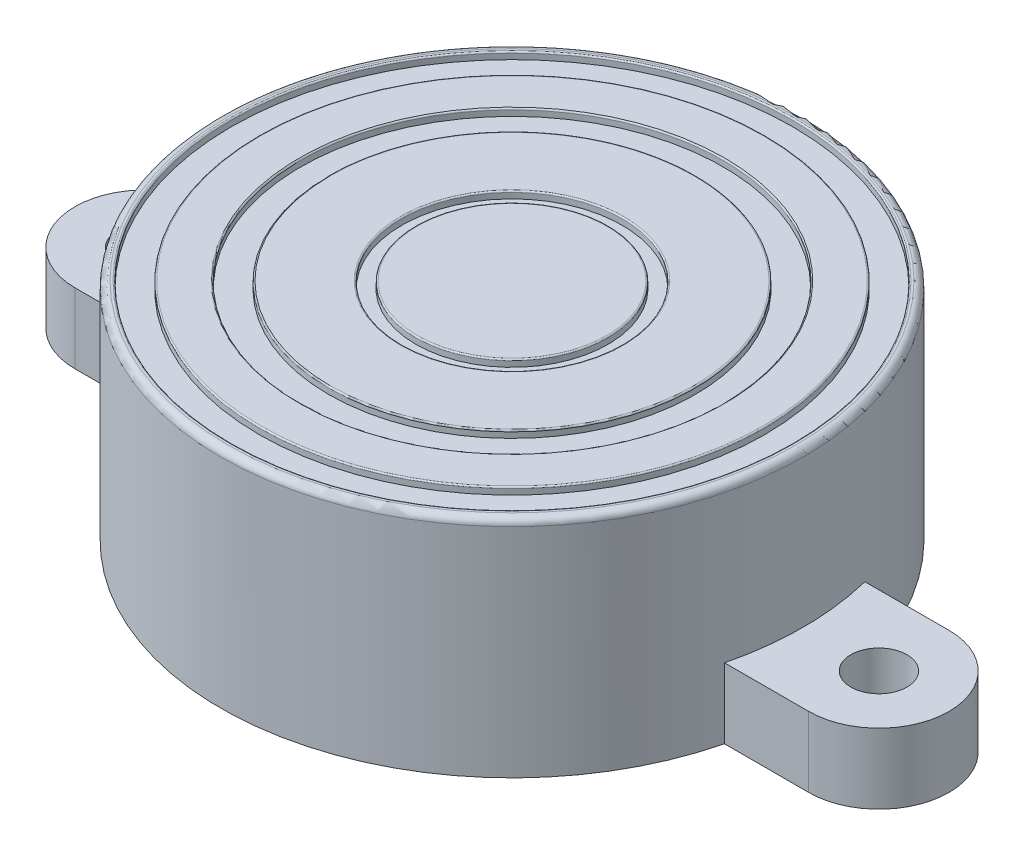
from build123d import *

# Parameters (mm, degrees)
SKETCH1_R           = 20.75
BOSS_EXTRUDE1_DEPTH = 16
SKETCH2_R           = 20
SKETCH2_R_2         = 18
SKETCH2_R_3         = 15.05
SKETCH2_R_4         = 13.05
SKETCH2_R_5         = 7.85
SKETCH2_R_6         = 6.85
CUT_EXTRUDE1_DEPTH  = 0.5
FILLET1_R           = 0.1
FILLET2_R           = 0.5
SKETCH3_R           = 5
BOSS_EXTRUDE2_DEPTH = 5
SKETCH4_R           = 2
CUT_EXTRUDE2_DEPTH  = 5


with BuildPart() as part:
    # Sketch1 → Boss-Extrude1 (new body)
    with BuildSketch(Plane(origin=(0, 0, 0), x_dir=(1, 0, 0), z_dir=(0, 1, 0))):
        with Locations(Location((0, 0, 0), (0, 0, 270))):
            Circle(SKETCH1_R)
    extrude(amount=BOSS_EXTRUDE1_DEPTH)

    # Sketch2 → Cut-Extrude1 (cut)
    with BuildSketch(Plane(origin=(0, 16, 0), x_dir=(1, 0, 0), z_dir=(0, 1, 0))):
        with Locations(Location((0, 0, 0), (0, 0, 270))):
            Circle(SKETCH2_R)
        with Locations(Location((0, 0, 0), (0, 0, 270))):
            Circle(SKETCH2_R_2, mode=Mode.SUBTRACT)
        with Locations(Location((0, 0, 0), (0, 0, 270))):
            Circle(SKETCH2_R_3)
        with Locations(Location((0, 0, 0), (0, 0, 270))):
            Circle(SKETCH2_R_4, mode=Mode.SUBTRACT)
        with Locations(Location((0, 0, 0), (0, 0, 270))):
            Circle(SKETCH2_R_5)
        with Locations(Location((0, 0, 0), (0, 0, 270))):
            Circle(SKETCH2_R_6, mode=Mode.SUBTRACT)
    extrude(amount=-CUT_EXTRUDE1_DEPTH, mode=Mode.SUBTRACT)

    # Fillet1
    fillet1_edges = [part.edges().sort_by_distance(p)[0] for p in [
        (0, 16, -18),
        (0, 16, -20),
        (0, 16, -13.05),
        (0, 16, -15.05),
        (0, 16, -6.85),
        (0, 16, -7.85),
    ]]
    fillet(fillet1_edges, radius=FILLET1_R)

    # Fillet2
    fillet2_edges = [part.edges().sort_by_distance(p)[0] for p in [
        (0, 16, -20.75),
    ]]
    fillet(fillet2_edges, radius=FILLET2_R)

    # Sketch3 → Boss-Extrude2 (add)
    with BuildSketch(Plane.XZ):
        with BuildLine():
            Line((-26.138582373, -5), (-20.138582373, -5))
            ThreePointArc((-20.138582373, -5), (-20.75, 0), (-20.138582373, 5))
            Line((-20.138582373, 5), (-26.138582373, 5))
            ThreePointArc((-26.138582373, 5), (-22.603048467, 3.535533906), (-21.138582373, 0))
            ThreePointArc((-21.138582373, 0), (-22.603048467, -3.535533906), (-26.138582373, -5))
        make_face()
        with BuildLine():
            ThreePointArc((20.75, 0), (20.596578408, -2.518622218), (20.138582373, -5))
            Line((20.138582373, -5), (26.138582373, -5))
            ThreePointArc((26.138582373, -5), (21.138582373, 0), (26.138582373, 5))
            Line((26.138582373, 5), (20.138582373, 5))
            ThreePointArc((20.138582373, 5), (20.596578408, 2.518622218), (20.75, 0))
        make_face()
        with Locations((-26.138582373, 0)):
            Circle(SKETCH3_R)
        with Locations((26.138582373, 0)):
            Circle(SKETCH3_R)
    extrude(amount=-BOSS_EXTRUDE2_DEPTH)

    # Sketch4 → Cut-Extrude2 (cut)
    with BuildSketch(Plane(origin=(0, 5, 0), x_dir=(1, 0, 0), z_dir=(0, 1, 0))):
        with Locations(Location((26.138582373, 0, 0), (0, 0, 270))):
            Circle(SKETCH4_R)
        with Locations(Location((-26.138582373, 0, 0), (0, 0, 270))):
            Circle(SKETCH4_R)
    extrude(amount=-CUT_EXTRUDE2_DEPTH, mode=Mode.SUBTRACT)


solid = part.part
